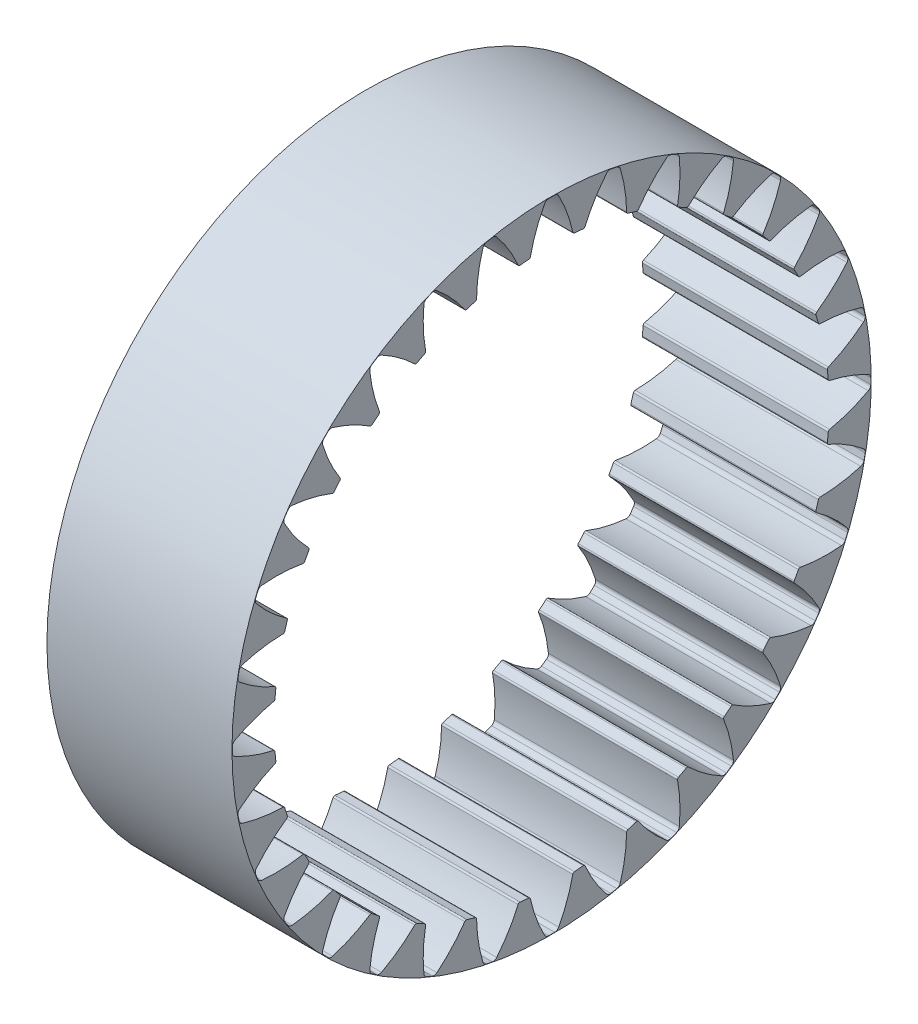
from build123d import *

# Parameters (mm, degrees)
BASPROSKE_W                = 10
BASPROSKE_H                = 2.2764
TOOTHCUT_DEPTH             = 27.399772611
BREAKS_R                   = 0.1
ROOTFILLETS_R              = 0.251
TEETHCUTS_COUNT            = 32
TEETHCUTS_ANGLE            = 348.75
BREAKS_OF_TEETHCUTS_R      = 0.1
ROOTFILLETS_OF_TEETHCUTS_R = 0.251


with BuildPart() as part:
    # BasProSke → Base-Revolve (revolve)
    with BuildSketch(Plane(origin=(0, 0, 0), x_dir=(1, 0, 0), z_dir=(0, 1, 0))):
        with Locations((5, 16.1382)):
            Rectangle(BASPROSKE_W, BASPROSKE_H)
    revolve(axis=Axis((-10, 0, 0), (1, 0, 0)))

    # TooCutSke → ToothCut (cut, through all)
    with BuildSketch(Plane(origin=(0, 0, 0), x_dir=(0, 0, -1), z_dir=(1, 0, 0))):
        with BuildLine():
            ThreePointArc((1.165703761, 14.929158714), (0.827716767, 16.121962966), (0.309494437, 17.248223508))
            ThreePointArc((0.309494437, 17.248223508), (0, 17.251), (-0.309494437, 17.248223508))
            ThreePointArc((-0.309494437, 17.248223508), (-0.827716767, 16.121962966), (-1.165703761, 14.929158714))
            ThreePointArc((-1.165703761, 14.929158714), (0, 14.9746), (1.165703761, 14.929158714))
        make_face()
    toothcut = extrude(amount=TOOTHCUT_DEPTH, mode=Mode.SUBTRACT)

    # Breaks
    breaks_edges = [part.edges().sort_by_distance(p)[0] for p in [
        (5, 14.95504442, 1.160450949),
        (5, 14.95504442, -1.160450949),
    ]]
    fillet(breaks_edges, radius=BREAKS_R)

    # RootFillets
    rootfillets_edges = [part.edges().sort_by_distance(p)[0] for p in [
        (5, 17.248223508, -0.309494437),
        (5, 17.248223508, 0.309494437),
    ]]
    fillet(rootfillets_edges, radius=ROOTFILLETS_R)

    # TeethCuts: ToothCut ×32 about axis
    teethcuts_axis = Axis((-10, 0, 0), (1, 0, 0))
    for i in range(1, TEETHCUTS_COUNT):
        add(toothcut.rotate(teethcuts_axis, i * TEETHCUTS_ANGLE / (TEETHCUTS_COUNT - 1)), mode=Mode.SUBTRACT)

    # Breaks of TeethCuts
    breaks_of_teethcuts_edges = [part.edges().sort_by_distance(p)[0] for p in [
        (5, 14.441294685, 4.055737641),
        (5, 14.894080184, 1.779431222),
        (5, 13.372574095, 6.79516461),
        (5, 14.260744799, 4.650930849),
        (5, 11.789952981, 9.273457214),
        (5, 13.07937699, 7.343697812),
        (5, 9.754250587, 11.395376057),
        (5, 11.395376057, 9.754250587),
        (5, 7.343697812, 13.07937699),
        (5, 9.273457214, 11.789952981),
        (5, 4.650930849, 14.260744799),
        (5, 6.79516461, 13.372574095),
        (5, 1.779431222, 14.894080184),
        (5, 4.055737641, 14.441294685),
        (5, -1.160450949, 14.95504442),
        (5, 1.160450949, 14.95504442),
        (5, -4.055737641, 14.441294685),
        (5, -1.779431222, 14.894080184),
        (5, -6.79516461, 13.372574095),
        (5, -4.650930849, 14.260744799),
        (5, -9.273457214, 11.789952981),
        (5, -7.343697812, 13.07937699),
        (5, -11.395376057, 9.754250587),
        (5, -9.754250587, 11.395376057),
        (5, -13.07937699, 7.343697812),
        (5, -11.789952981, 9.273457214),
        (5, -14.260744799, 4.650930849),
        (5, -13.372574095, 6.79516461),
        (5, -14.894080184, 1.779431222),
        (5, -14.441294685, 4.055737641),
        (5, -14.95504442, -1.160450949),
        (5, -14.95504442, 1.160450949),
        (5, -14.441294685, -4.055737641),
        (5, -14.894080184, -1.779431222),
        (5, -13.372574095, -6.79516461),
        (5, -14.260744799, -4.650930849),
        (5, -11.789952981, -9.273457214),
        (5, -13.07937699, -7.343697812),
        (5, -9.754250587, -11.395376057),
        (5, -11.395376057, -9.754250587),
        (5, -7.343697812, -13.07937699),
        (5, -9.273457214, -11.789952981),
        (5, -4.650930849, -14.260744799),
        (5, -6.79516461, -13.372574095),
        (5, -1.779431222, -14.894080184),
        (5, -4.055737641, -14.441294685),
        (5, 1.160450949, -14.95504442),
        (5, -1.160450949, -14.95504442),
        (5, 4.055737641, -14.441294685),
        (5, 1.779431222, -14.894080184),
        (5, 6.79516461, -13.372574095),
        (5, 4.650930849, -14.260744799),
        (5, 9.273457214, -11.789952981),
        (5, 7.343697812, -13.07937699),
        (5, 11.395376057, -9.754250587),
        (5, 9.754250587, -11.395376057),
        (5, 13.07937699, -7.343697812),
        (5, 11.789952981, -9.273457214),
        (5, 14.260744799, -4.650930849),
        (5, 13.372574095, -6.79516461),
        (5, 14.894080184, -1.779431222),
        (5, 14.441294685, -4.055737641),
    ]]
    fillet(breaks_of_teethcuts_edges, radius=BREAKS_OF_TEETHCUTS_R)

    # RootFillets of TeethCuts
    rootfillets_of_teethcuts_edges = [part.edges().sort_by_distance(p)[0] for p in [
        (5, 16.977183099, 3.06141389),
        (5, 16.856424361, 3.668509067),
        (5, 16.053719065, 6.314673798),
        (5, 15.816842278, 6.88654495),
        (5, 14.51331961, 9.325264334),
        (5, 14.169427817, 9.839934773),
        (5, 12.415181421, 11.977490191),
        (5, 11.977490191, 12.415181421),
        (5, 9.839934773, 14.169427817),
        (5, 9.325264334, 14.51331961),
        (5, 6.88654495, 15.816842278),
        (5, 6.314673798, 16.053719065),
        (5, 3.668509067, 16.856424361),
        (5, 3.06141389, 16.977183099),
        (5, 0.309494437, 17.248223508),
        (5, -0.309494437, 17.248223508),
        (5, -3.06141389, 16.977183099),
        (5, -3.668509067, 16.856424361),
        (5, -6.314673798, 16.053719065),
        (5, -6.88654495, 15.816842278),
        (5, -9.325264334, 14.51331961),
        (5, -9.839934773, 14.169427817),
        (5, -11.977490191, 12.415181421),
        (5, -12.415181421, 11.977490191),
        (5, -14.169427817, 9.839934773),
        (5, -14.51331961, 9.325264334),
        (5, -15.816842278, 6.88654495),
        (5, -16.053719065, 6.314673798),
        (5, -16.856424361, 3.668509067),
        (5, -16.977183099, 3.06141389),
        (5, -17.248223508, 0.309494437),
        (5, -17.248223508, -0.309494437),
        (5, -16.977183099, -3.06141389),
        (5, -16.856424361, -3.668509067),
        (5, -16.053719065, -6.314673798),
        (5, -15.816842278, -6.88654495),
        (5, -14.51331961, -9.325264334),
        (5, -14.169427817, -9.839934773),
        (5, -12.415181421, -11.977490191),
        (5, -11.977490191, -12.415181421),
        (5, -9.839934773, -14.169427817),
        (5, -9.325264334, -14.51331961),
        (5, -6.88654495, -15.816842278),
        (5, -6.314673798, -16.053719065),
        (5, -3.668509067, -16.856424361),
        (5, -3.06141389, -16.977183099),
        (5, -0.309494437, -17.248223508),
        (5, 0.309494437, -17.248223508),
        (5, 3.06141389, -16.977183099),
        (5, 3.668509067, -16.856424361),
        (5, 6.314673798, -16.053719065),
        (5, 6.88654495, -15.816842278),
        (5, 9.325264334, -14.51331961),
        (5, 9.839934773, -14.169427817),
        (5, 11.977490191, -12.415181421),
        (5, 12.415181421, -11.977490191),
        (5, 14.169427817, -9.839934773),
        (5, 14.51331961, -9.325264334),
        (5, 15.816842278, -6.88654495),
        (5, 16.053719065, -6.314673798),
        (5, 16.856424361, -3.668509067),
        (5, 16.977183099, -3.06141389),
    ]]
    fillet(rootfillets_of_teethcuts_edges, radius=ROOTFILLETS_OF_TEETHCUTS_R)


solid = part.part
